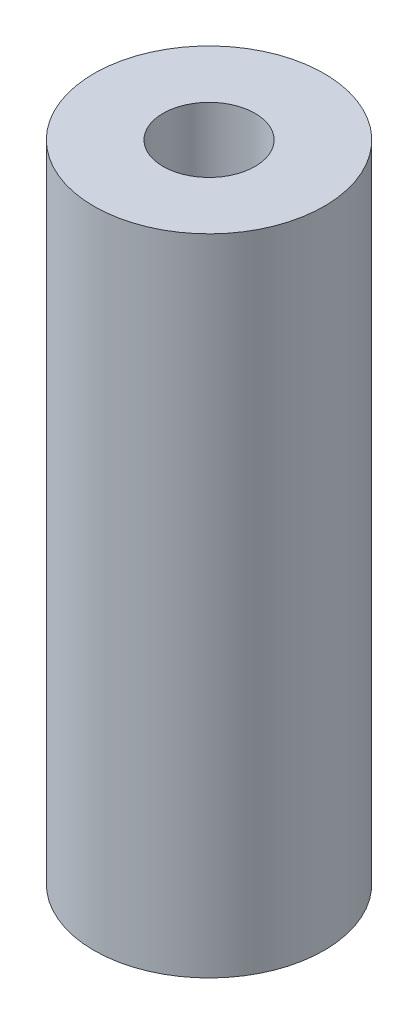
from build123d import *

# Parameters (mm, degrees)
SKETCH1_R           = 2.5
SKETCH1_R_2         = 1
BOSS_EXTRUDE1_DEPTH = 14


with BuildPart() as part:
    # Sketch1 → Boss-Extrude1 (new body)
    with BuildSketch(Plane(origin=(0, 0, 0), x_dir=(1, 0, 0), z_dir=(0, 1, 0))):
        Circle(SKETCH1_R)
        Circle(SKETCH1_R_2, mode=Mode.SUBTRACT)
    extrude(amount=BOSS_EXTRUDE1_DEPTH)


solid = part.part
